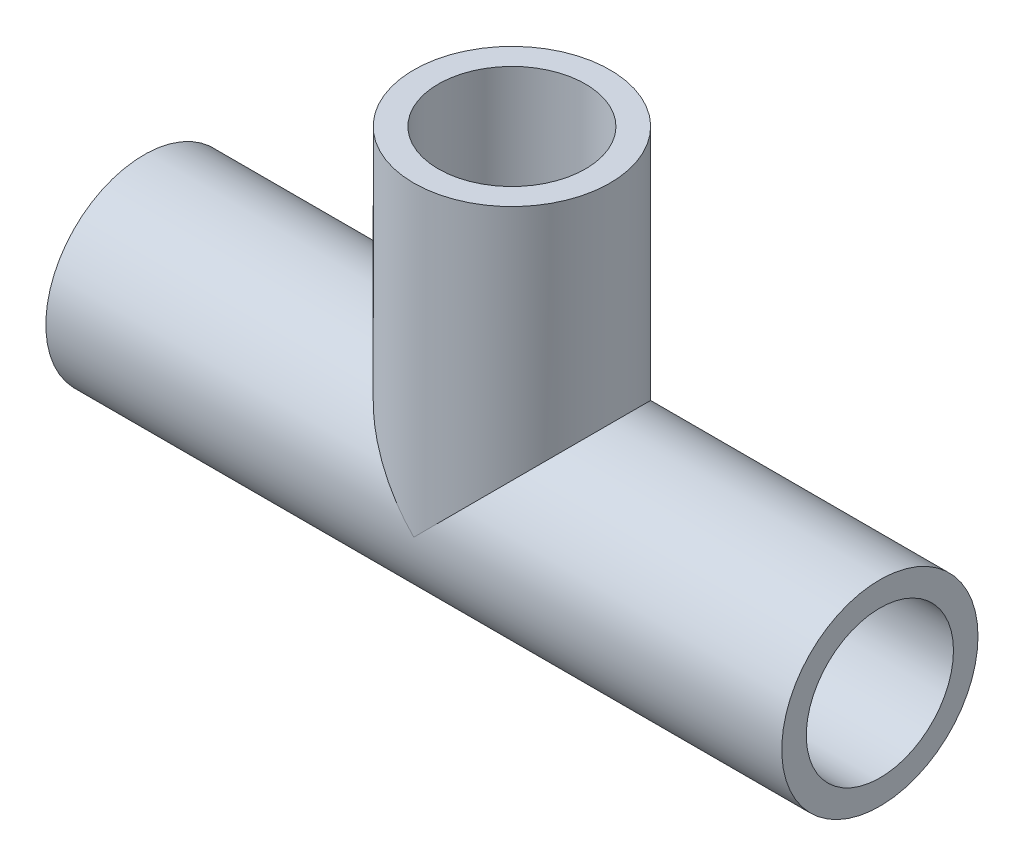
from build123d import *

# Parameters (mm, degrees)
SKETCH1_R           = 8
SKETCH1_R_2         = 6
BOSS_EXTRUDE1_DEPTH = 30
BOSS_EXTRUDE2_REACH = 35
SKETCH3_R           = 8
SKETCH4_R           = 6
CUT_EXTRUDE1_DEPTH  = 25


with BuildPart() as part:
    # Sketch1 → Boss-Extrude1 (new body, symmetric)
    with BuildSketch(Plane(origin=(0, 0, 0), x_dir=(0, 0, -1), z_dir=(1, 0, 0))):
        Circle(SKETCH1_R)
        Circle(SKETCH1_R_2, mode=Mode.SUBTRACT)
    extrude(amount=BOSS_EXTRUDE1_DEPTH, both=True)

    # Sketch3 → Boss-Extrude2 (add, up to next)
    with BuildSketch(Plane(origin=(0, 25, 0), x_dir=(1, 0, 0), z_dir=(0, 1, 0)), mode=Mode.PRIVATE) as boss_extrude2_sk1:
        Circle(SKETCH3_R)
    boss_extrude2_tool1 = extrude(boss_extrude2_sk1.sketch, amount=-BOSS_EXTRUDE2_REACH, mode=Mode.PRIVATE) - part.part
    add(boss_extrude2_tool1.solids().sort_by_distance((0, 25, 0))[0])

    # Sketch4 → Cut-Extrude1 (cut)
    with BuildSketch(Plane(origin=(0, 25, 0), x_dir=(1, 0, 0), z_dir=(0, 1, 0))):
        Circle(SKETCH4_R)
    extrude(amount=-CUT_EXTRUDE1_DEPTH, mode=Mode.SUBTRACT)


solid = part.part
